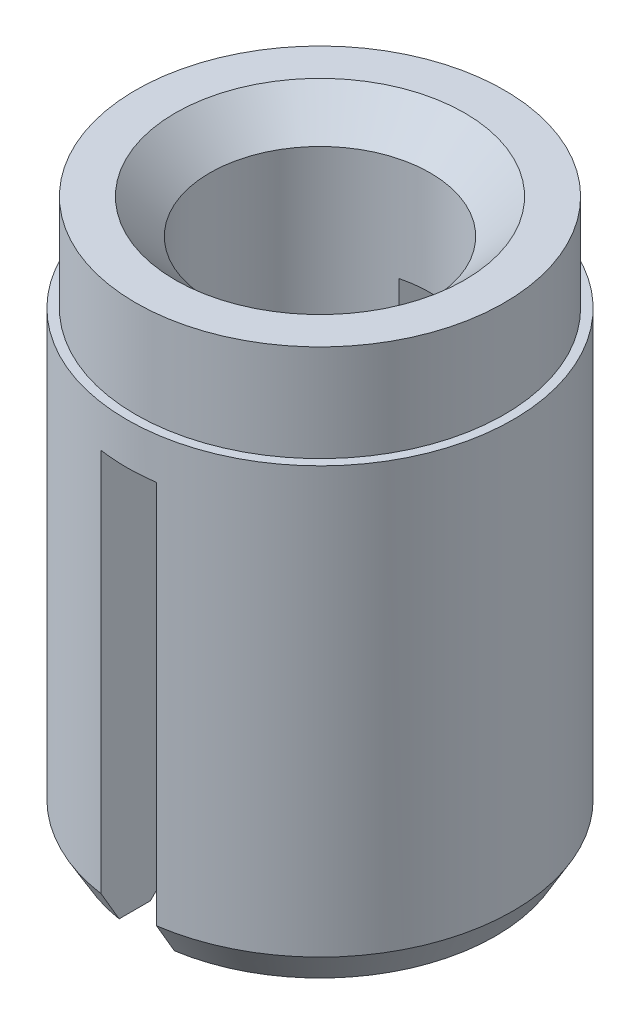
from build123d import *

# Parameters (mm, degrees)
SKETCH1_R           = 3.175
EXTRUDE1_DEPTH      = 9.525
EXTRUDE2_START      = -9.525
SKETCH1_4_R         = 3.3274
SKETCH1_4_R_2       = 3.175
EXTRUDE2_DEPTH      = 7.858125
EXTRUDE3_START      = -9.525
SKETCH4_R           = 1.897444252
EXTRUDE3_DEPTH      = 9.525
CHAMFER1_SIZE       = 0.5953125
CHAMFER2_SIZE       = 0.3048
CHAMFER2_SIZE2      = 0.527929086
SKETCH8_W           = 0.9525
SKETCH8_H           = 7.14375
EXTRUDE4_DEPTH      = 4.3274
EXTRUDE4_DEPTH_BACK = 4.3274


with BuildPart() as part:
    # Sketch1 → Extrude1 (new body)
    with BuildSketch(Plane(origin=(0, 0, 0), x_dir=(1, 0, 0), z_dir=(0, 1, 0))):
        Circle(SKETCH1_R)
    extrude(amount=-EXTRUDE1_DEPTH)

    # Sketch1_4 → Extrude2 (add)
    with BuildSketch(Plane(origin=(0, 0, 0), x_dir=(1, 0, 0), z_dir=(0, 1, 0)).offset(EXTRUDE2_START)):
        Circle(SKETCH1_4_R)
        Circle(SKETCH1_4_R_2, mode=Mode.SUBTRACT)
    extrude(amount=EXTRUDE2_DEPTH)

    # Sketch4 → Extrude3 (cut)
    with BuildSketch(Plane(origin=(0, 0, 0), x_dir=(1, 0, 0), z_dir=(0, 1, 0)).offset(EXTRUDE3_START)):
        Circle(SKETCH4_R)
    extrude(amount=EXTRUDE3_DEPTH, mode=Mode.SUBTRACT)

    # Chamfer1
    chamfer1_edges = [part.edges().sort_by_distance(p)[0] for p in [
        (-1.897444252, -9.525, 0),
        (-1.897444252, 0, 0),
    ]]
    chamfer(chamfer1_edges, length=CHAMFER1_SIZE)

    # Chamfer2
    chamfer2_edges = [part.edges().sort_by_distance(p)[0] for p in [
        (-3.3274, -9.525, 0),
    ]]
    chamfer2_side = [part.faces().sort_by_distance(p)[0] for p in [
        (-2.586869836, -9.525, 0),
    ]]
    chamfer(chamfer2_edges, length=CHAMFER2_SIZE, length2=CHAMFER2_SIZE2, reference=chamfer2_side[0])

    # Sketch8 → Extrude4 (cut, two sides)
    with BuildSketch(Plane.XY) as extrude4_sk:
        with Locations((0, -5.953125)):
            Rectangle(SKETCH8_W, SKETCH8_H)
    extrude(amount=EXTRUDE4_DEPTH, mode=Mode.SUBTRACT)
    extrude(extrude4_sk.sketch, amount=-EXTRUDE4_DEPTH_BACK, mode=Mode.SUBTRACT)


solid = part.part
